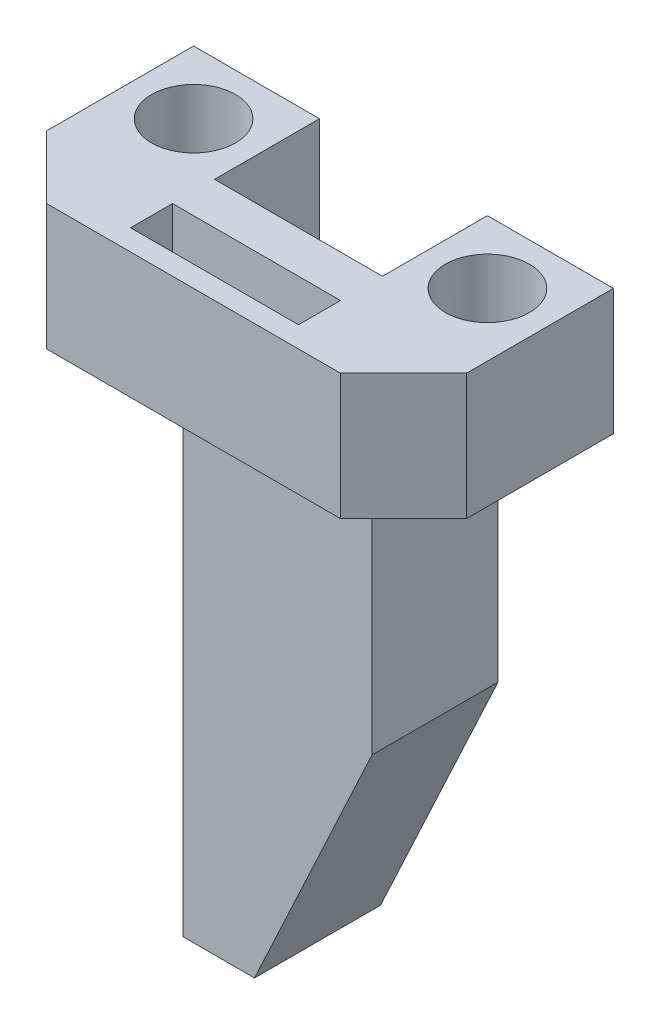
from build123d import *

# Parameters (mm, degrees)
EXTRUDE_1_DEPTH     = 6
CUT_EXTRUDE_3_REACH = 8
SKETCH_2_R          = 2
SKETCH_2_W          = 8
SKETCH_2_H          = 2
CHAMFER_1_SIZE      = 3
SKETCH_5_W          = 9
SKETCH_5_H          = 6
EXTRUDE_5_DEPTH     = 25
CHAMFER_3_SIZE      = 12
CHAMFER_3_SIZE2     = 5.595691898


with BuildPart() as part:
    # 草图1 → 凸台-拉伸1 (new body)
    with BuildSketch(Plane(origin=(0, 0, 0), x_dir=(1, 0, 0), z_dir=(0, 1, 0))):
        Polygon((-4, 5), (-4, 10), (-10, 10), (-10, 5), (-10, 0), (10, 0), (10, 5), (10, 10), (4, 10), (4, 5), align=None)
    extrude(amount=EXTRUDE_1_DEPTH)

    # 草图2 → 切除-拉伸3 (cut, up to next)
    with BuildSketch(Plane(origin=(0, 6, 0), x_dir=(1, 0, 0), z_dir=(0, 1, 0)), mode=Mode.PRIVATE) as cut_extrude_3_sk1:
        with Locations((-7, 7)):
            Circle(SKETCH_2_R)
    cut_extrude_3_tool1 = extrude(cut_extrude_3_sk1.sketch, amount=-CUT_EXTRUDE_3_REACH, mode=Mode.PRIVATE) & part.part
    add(cut_extrude_3_tool1.solids().sort_by_distance((-7, 6, -7))[0], mode=Mode.SUBTRACT)
    # 草图2 → 切除-拉伸3 (cut, up to next)
    with BuildSketch(Plane(origin=(0, 6, 0), x_dir=(1, 0, 0), z_dir=(0, 1, 0)), mode=Mode.PRIVATE) as cut_extrude_3_sk2:
        with Locations((7, 7)):
            Circle(SKETCH_2_R)
    cut_extrude_3_tool2 = extrude(cut_extrude_3_sk2.sketch, amount=-CUT_EXTRUDE_3_REACH, mode=Mode.PRIVATE) & part.part
    add(cut_extrude_3_tool2.solids().sort_by_distance((7, 6, -7))[0], mode=Mode.SUBTRACT)
    # 草图2 → 切除-拉伸3 (cut, up to next)
    with BuildSketch(Plane(origin=(0, 6, 0), x_dir=(1, 0, 0), z_dir=(0, 1, 0)), mode=Mode.PRIVATE) as cut_extrude_3_sk3:
        with Locations((0, 2)):
            Rectangle(SKETCH_2_W, SKETCH_2_H)
    cut_extrude_3_tool3 = extrude(cut_extrude_3_sk3.sketch, amount=-CUT_EXTRUDE_3_REACH, mode=Mode.PRIVATE) & part.part
    add(cut_extrude_3_tool3.solids().sort_by_distance((0, 6, -2))[0], mode=Mode.SUBTRACT)

    # 倒角1
    chamfer_1_edges = [part.edges().sort_by_distance(p)[0] for p in [
        (10, 3, 0),
        (-10, 3, 0),
    ]]
    chamfer(chamfer_1_edges, length=CHAMFER_1_SIZE)

    # 草图5 → 凸台-拉伸5 (add)
    with BuildSketch(Plane.XZ):
        with Locations((0, -7)):
            Rectangle(SKETCH_5_W, SKETCH_5_H)
    extrude(amount=EXTRUDE_5_DEPTH)

    # 倒角3
    chamfer_3_edges = [part.edges().sort_by_distance(p)[0] for p in [
        (4.5, -25, -7),
    ]]
    chamfer_3_side = [part.faces().sort_by_distance(p)[0] for p in [
        (4.5, -12.5, -7),
    ]]
    chamfer(chamfer_3_edges, length=CHAMFER_3_SIZE, length2=CHAMFER_3_SIZE2, reference=chamfer_3_side[0])


solid = part.part
